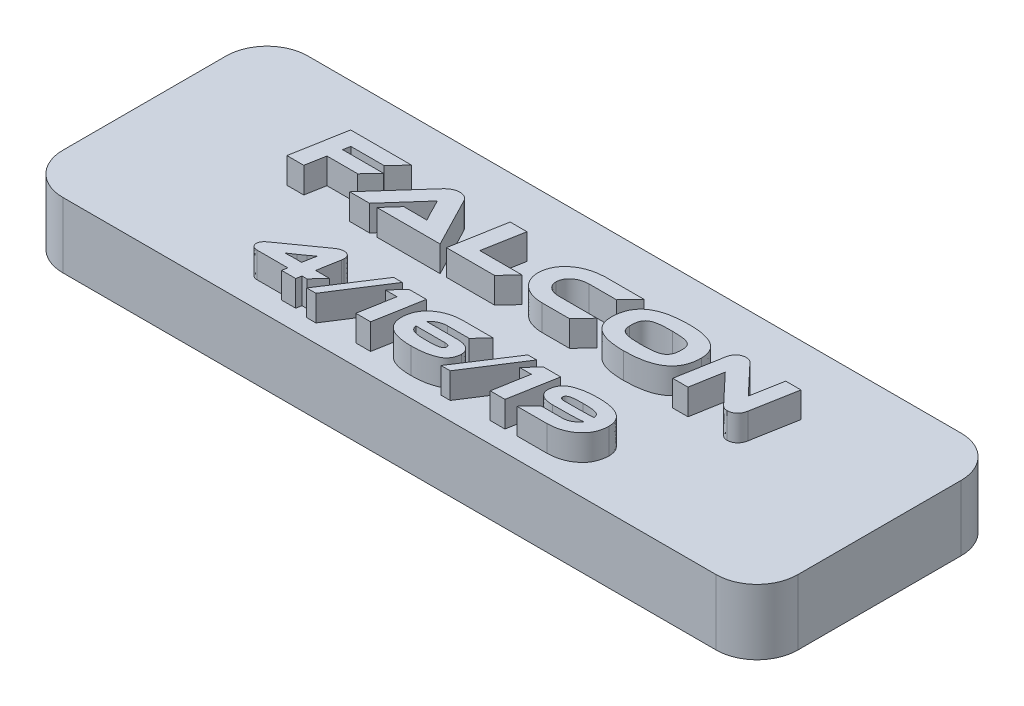
from build123d import *

# Parameters (mm, degrees)
SKETCH1_W           = 57.15
SKETCH1_H           = 19.05
BOSS_EXTRUDE1_DEPTH = 5.08
FILLET1_R           = 3.175
BOSS_EXTRUDE2_DEPTH = 2
SKETCH4_R           = 0.9
CUT_EXTRUDE1_DEPTH  = 4


with BuildPart() as part:
    # Sketch1 → Boss-Extrude1 (new body)
    with BuildSketch(Plane(origin=(0, 0, 0), x_dir=(1, 0, 0), z_dir=(0, 1, 0))):
        Rectangle(SKETCH1_W, SKETCH1_H)
    extrude(amount=BOSS_EXTRUDE1_DEPTH)

    # Fillet1
    fillet1_edges = [part.edges().sort_by_distance(p)[0] for p in [
        (-28.575, 2.54, -9.525),
        (-28.575, 2.54, 9.525),
        (28.575, 2.54, 9.525),
        (28.575, 2.54, -9.525),
    ]]
    fillet(fillet1_edges, radius=FILLET1_R)

    # Sketch3 → Boss-Extrude2 (add)
    with BuildSketch(Plane(origin=(0, 5.08, 0), x_dir=(1, 0, 0), z_dir=(0, 1, 0))):
        with BuildLine():
            add(Edge.make_bspline(
                [(16.780266279, -0.054850168), (16.828009676, -0.053307756), (16.922711817, -0.05024828), (17.060768199, -0.013632566), (17.191682911, 0.045846546), (17.292948445, 0.114571327), (17.369813108, 0.180074196), (17.42146539, 0.239380304), (17.469141377, 0.304525883), (17.512820124, 0.37632488), (17.549549759, 0.456142621), (17.58266638, 0.542520209), (17.611096033, 0.636006561), (17.625642107, 0.701351948), (17.633127874, 0.73498029)],
                knots=[0, 0, 0, 0, 0.000142918, 0.000283487, 0.000425039, 0.000572601, 0.000649052, 0.000727397, 0.000807848, 0.000891096, 0.000979017, 0.001071034, 0.001168489, 0.001271817, 0.001271817, 0.001271817, 0.001271817], degree=3))
            Line((17.633127874, 0.73498029), (18.258850622, 4.208766837))
            Line((18.258850622, 4.208766837), (17.070928158, 4.208766837))
            Line((17.070928158, 4.208766837), (16.628616603, 1.744535481))
            Line((16.628616603, 1.744535481), (14.448652508, 4.051761679))
            add(Edge.make_bspline(
                [(14.448652508, 4.051761679), (14.427813381, 4.071861366), (14.387749108, 4.110504029), (14.325171244, 4.159915527), (14.263133498, 4.198286334), (14.183296116, 4.234148727), (14.083019548, 4.262967857), (14.001697117, 4.265244744), (13.961883043, 4.266359469)],
                knots=[0, 0, 0, 0, 8.6821e-05, 0.000166918, 0.000238724, 0.000304999, 0.000429193, 0.000548317, 0.000548317, 0.000548317, 0.000548317], degree=3))
            add(Edge.make_bspline(
                [(13.961883043, 4.266359469), (13.912605999, 4.264808905), (13.815559411, 4.261755212), (13.674416698, 4.225895662), (13.540680994, 4.169094021), (13.438121991, 4.10078741), (13.361606759, 4.035125752), (13.309731394, 3.976716804), (13.261583005, 3.912614286), (13.219520308, 3.840326612), (13.182204708, 3.76109782), (13.150633382, 3.674633708), (13.122418598, 3.581734028), (13.109335945, 3.516584051), (13.102577729, 3.482928986)],
                knots=[0, 0, 0, 0, 0.000147522, 0.000290531, 0.000433852, 0.000581668, 0.000658119, 0.000735785, 0.0008155, 0.00089828, 0.000986201, 0.001077895, 0.001174211, 0.001277134, 0.001277134, 0.001277134, 0.001277134], degree=3))
            Line((13.102577729, 3.482928986), (12.48984419, 0.003655726))
            Line((12.48984419, 0.003655726), (13.677766654, 0.003655726))
            Line((13.677766654, 0.003655726), (14.113759473, 2.467622834))
            Line((14.113759473, 2.467622834), (16.293723568, 0.160396636))
            add(Edge.make_bspline(
                [(16.293723568, 0.160396636), (16.314440673, 0.140042889), (16.354045572, 0.101132624), (16.416177124, 0.052046216), (16.47573695, 0.012533377), (16.553265822, -0.024191848), (16.654960002, -0.051598076), (16.737989767, -0.054359084), (16.780266279, -0.054850168)],
                knots=[0, 0, 0, 0, 8.7067e-05, 0.000166446, 0.000237191, 0.000300979, 0.000423168, 0.000549653, 0.000549653, 0.000549653, 0.000549653], degree=3))
        make_face()
        with BuildLine():
            add(Edge.make_bspline(
                [(9.496039689, 4.264853435), (9.422966975, 4.264150041), (9.279462864, 4.262768679), (9.068001233, 4.255304453), (8.863725494, 4.243828802), (8.666531346, 4.226275073), (8.476304033, 4.204448808), (8.292999458, 4.178135377), (8.116702708, 4.146346882), (7.947565312, 4.108703546), (7.785589212, 4.066841285), (7.630726648, 4.020018599), (7.482516888, 3.969271115), (7.341257794, 3.912462076), (7.207363574, 3.850145336), (7.079594109, 3.784672178), (6.959544845, 3.713307743), (6.847056036, 3.636054084), (6.740530204, 3.555015487), (6.641809484, 3.467997248), (6.549955969, 3.375795294), (6.463884658, 3.27972572), (6.38614356, 3.176938462), (6.313458319, 3.070861845), (6.250017547, 2.958180712), (6.190488837, 2.842029764), (6.139796027, 2.71956376), (6.096078177, 2.592115874), (6.058140919, 2.460138961), (6.02847549, 2.322911611), (6.004600111, 2.180763117), (5.987270576, 2.033740252), (5.976946139, 1.881481624), (5.976205213, 1.778351657), (5.975828551, 1.725923865)],
                knots=[0, 0, 0, 0, 0.00021922, 0.000430517, 0.000634719, 0.000832939, 0.001024345, 0.001209088, 0.001388397, 0.001561619, 0.0017288, 0.001890173, 0.002046865, 0.002198625, 0.002346687, 0.00248979, 0.002629165, 0.002765325, 0.002898982, 0.003030471, 0.003159752, 0.003289265, 0.003417071, 0.003546125, 0.003674706, 0.003804712, 0.003937476, 0.004071906, 0.004208776, 0.004349179, 0.004492852, 0.004641052, 0.004793135, 0.004950393, 0.004950393, 0.004950393, 0.004950393], degree=3))
            add(Edge.make_bspline(
                [(5.975828551, 1.725923865), (5.977756992, 1.652651179), (5.981498211, 1.510500548), (6.015537081, 1.304743113), (6.068725934, 1.113533359), (6.14442286, 0.936607339), (6.241975517, 0.774301847), (6.361810325, 0.627005612), (6.503767588, 0.495143384), (6.666657174, 0.377875494), (6.851095344, 0.275513814), (7.05651962, 0.187096535), (7.282704131, 0.111278664), (7.53053192, 0.05083109), (7.798977563, 0.003624777), (8.088662872, -0.029580863), (8.399569375, -0.049844784), (8.614046343, -0.051940053), (8.724691401, -0.053020966)],
                knots=[0, 0, 0, 0, 0.000219671, 0.000426167, 0.000623813, 0.000813827, 0.001001645, 0.001190103, 0.001381548, 0.00158123, 0.001790776, 0.002013083, 0.002251287, 0.002505594, 0.002777627, 0.003068474, 0.003379936, 0.003711836, 0.003711836, 0.003711836, 0.003711836], degree=3))
            add(Edge.make_bspline(
                [(8.724691401, -0.053020966), (8.797526067, -0.052455169), (8.940794073, -0.051342229), (9.152314687, -0.043724787), (9.356604575, -0.032438481), (9.553772066, -0.014624257), (9.744093932, 0.006825126), (9.927265684, 0.034388638), (10.103600918, 0.066140884), (10.272466839, 0.103671999), (10.434647572, 0.145843098), (10.590159049, 0.191939017), (10.738202104, 0.24436261), (10.879477809, 0.30061376), (11.013060988, 0.363320067), (11.140472785, 0.429548791), (11.260223208, 0.501958418), (11.373001359, 0.579052293), (11.479431476, 0.660209293), (11.578536557, 0.747143393), (11.669745373, 0.84029394), (11.756172858, 0.93631177), (11.833868558, 1.03914999), (11.90652582, 1.145233071), (11.97025848, 1.258074334), (12.029279808, 1.374784654), (12.080257156, 1.497412041), (12.123929499, 1.624884051), (12.161864706, 1.756856749), (12.191650752, 1.894369804), (12.215319165, 2.036857562), (12.232761347, 2.184166254), (12.243064568, 2.336428379), (12.24380842, 2.439557863), (12.24418657, 2.491985411)],
                knots=[0, 0, 0, 0, 0.0002185, 0.000429796, 0.000634912, 0.000832221, 0.001023627, 0.001209407, 0.001387817, 0.001561039, 0.001728219, 0.001890468, 0.002047461, 0.002199222, 0.002346454, 0.00248998, 0.002629824, 0.002765984, 0.002899642, 0.003031131, 0.00316106, 0.003290573, 0.003418378, 0.003547433, 0.003676014, 0.003806837, 0.003939601, 0.004074031, 0.004210901, 0.004351303, 0.004495879, 0.004644079, 0.004796161, 0.00495342, 0.00495342, 0.00495342, 0.00495342], degree=3))
            add(Edge.make_bspline(
                [(12.24418657, 2.491985411), (12.242105639, 2.564930001), (12.238053197, 2.706983534), (12.205921842, 2.912703512), (12.151924556, 3.104122883), (12.075935536, 3.280748696), (11.977982074, 3.44245971), (11.858843079, 3.589369287), (11.717433844, 3.721034434), (11.553921911, 3.837071522), (11.36988913, 3.940135668), (11.163846554, 4.0266221), (10.937979748, 4.102333874), (10.689961762, 4.161421518), (10.421343254, 4.208718585), (10.131386896, 4.242297194), (9.820406294, 4.261022072), (9.605961896, 4.263336881), (9.496039689, 4.264853435)],
                knots=[0, 0, 0, 0, 0.000218758, 0.000426013, 0.00062278, 0.000813995, 0.001001031, 0.001188203, 0.001379648, 0.001578795, 0.001788342, 0.002011126, 0.002248172, 0.002502261, 0.002775194, 0.003066041, 0.003377445, 0.003709345, 0.003709345, 0.003709345, 0.003709345], degree=3))
        make_face()
        with BuildLine():
            add(Edge.make_bspline(
                [(8.91471593, 1.047030173), (8.846195292, 1.04660261), (8.714276038, 1.045779446), (8.523416215, 1.049733712), (8.347251806, 1.061186797), (8.185148154, 1.075736974), (8.037480131, 1.097737934), (7.904153413, 1.125013299), (7.784313682, 1.156348623), (7.678448073, 1.194530349), (7.584599376, 1.240026498), (7.504703992, 1.297252332), (7.436098008, 1.363776891), (7.382195021, 1.441900597), (7.339325071, 1.529303822), (7.309500361, 1.627061382), (7.291915256, 1.735031597), (7.29090669, 1.81026116), (7.29038285, 1.849334734)],
                knots=[0, 0, 0, 0, 0.000205565, 0.000395764, 0.000572537, 0.000735087, 0.000883892, 0.001020147, 0.001143219, 0.001255139, 0.001357344, 0.001455005, 0.001548736, 0.001642574, 0.001738242, 0.001839729, 0.001948086, 0.002065187, 0.002065187, 0.002065187, 0.002065187], degree=3))
            add(Edge.make_bspline(
                [(7.29038285, 1.849334734), (7.28873433, 1.911811071), (7.28557848, 2.031412847), (7.297476265, 2.203375738), (7.322437279, 2.359667266), (7.361285958, 2.50079582), (7.414551249, 2.626166729), (7.480115864, 2.737052728), (7.561928012, 2.83042282), (7.641134092, 2.895436203), (7.71178484, 2.940784123), (7.772281923, 2.971515459), (7.839372447, 2.999666566), (7.912637304, 3.026084681), (7.99215494, 3.05083148), (8.078211737, 3.072755525), (8.171151839, 3.09131218), (8.270244238, 3.110411596), (8.376577823, 3.124111193), (8.48896002, 3.137374608), (8.608211033, 3.147018552), (8.733772388, 3.155167115), (8.866021782, 3.161792983), (9.004705933, 3.165320712), (9.150079568, 3.166041701), (9.249111973, 3.165221911), (9.299694638, 3.164803188)],
                knots=[0, 0, 0, 0, 0.000187411, 0.00035877, 0.00051627, 0.000661555, 0.000796714, 0.00092386, 0.001046319, 0.001167112, 0.001230003, 0.001297872, 0.001370374, 0.001448163, 0.001531436, 0.001620123, 0.001714428, 0.001815734, 0.00192278, 0.002035947, 0.002155212, 0.002281633, 0.002413427, 0.002552426, 0.00269778, 0.002849532, 0.002849532, 0.002849532, 0.002849532], degree=3))
            add(Edge.make_bspline(
                [(9.299694638, 3.164803188), (9.368559888, 3.165086646), (9.501737734, 3.165634822), (9.694160203, 3.161832074), (9.871852792, 3.150341942), (10.035147755, 3.135653139), (10.183797083, 3.114010286), (10.317931417, 3.086275793), (10.437965422, 3.055550786), (10.54358555, 3.01670025), (10.637134078, 2.971781209), (10.7163785, 2.913989507), (10.784704553, 2.847457656), (10.839901962, 2.770130915), (10.881548215, 2.682069422), (10.910305027, 2.584313015), (10.928162923, 2.476491904), (10.929129986, 2.401253582), (10.929632271, 2.362175459)],
                knots=[0, 0, 0, 0, 0.000206599, 0.00039954, 0.000577225, 0.000740685, 0.000891298, 0.001027553, 0.001151508, 0.001262569, 0.001364775, 0.001461693, 0.001555424, 0.00164979, 0.00174506, 0.001846279, 0.001954636, 0.002071737, 0.002071737, 0.002071737, 0.002071737], degree=3))
            add(Edge.make_bspline(
                [(10.929632271, 2.362175459), (10.931254644, 2.300007823), (10.934359778, 2.181022384), (10.922788079, 2.009565903), (10.896561285, 1.85401663), (10.857628122, 1.713235889), (10.804733494, 1.587793863), (10.73796533, 1.477427264), (10.655936337, 1.383606431), (10.576469765, 1.317707612), (10.504731357, 1.272767382), (10.443886333, 1.241979786), (10.377216755, 1.212524455), (10.303432095, 1.186264377), (10.223566102, 1.161664348), (10.136822766, 1.139884782), (10.043906067, 1.119635522), (9.944068854, 1.102726509), (9.83806692, 1.086938186), (9.725249672, 1.074209563), (9.606013167, 1.064550242), (9.480151635, 1.056272217), (9.347897448, 1.049750773), (9.20891042, 1.046182113), (9.063536387, 1.045470465), (8.964504037, 1.046288949), (8.91471593, 1.047030173)],
                knots=[0, 0, 0, 0, 0.000186496, 0.000356944, 0.000514595, 0.000659, 0.000794159, 0.000921781, 0.00104424, 0.00116632, 0.001229983, 0.001297853, 0.001370716, 0.001448505, 0.001532652, 0.001621339, 0.001716727, 0.001817873, 0.001925047, 0.002038214, 0.00215839, 0.002283899, 0.002416606, 0.002555606, 0.002700959, 0.002852711, 0.002852711, 0.002852711, 0.002852711], degree=3))
        make_face(mode=Mode.SUBTRACT)
        with BuildLine():
            add(Edge.make_bspline(
                [(2.533352691, 1.105536066), (2.493631661, 1.106368572), (2.416216179, 1.107991107), (2.303389092, 1.120099472), (2.197144099, 1.139341634), (2.09673251, 1.164731953), (2.002199599, 1.197730851), (1.913689506, 1.237674392), (1.831391916, 1.284870974), (1.755586613, 1.338214411), (1.688115375, 1.398892985), (1.628130206, 1.463686553), (1.577372546, 1.534061863), (1.534888764, 1.609307897), (1.50205177, 1.690172386), (1.478239958, 1.775740301), (1.463466337, 1.866215268), (1.460506531, 1.928202108), (1.458990725, 1.95994744)],
                knots=[0, 0, 0, 0, 0.000119146, 0.000232213, 0.000339979, 0.000442857, 0.0005426, 0.00063997, 0.000733741, 0.000826832, 0.000917476, 0.001005473, 0.001091233, 0.001177183, 0.0012641, 0.001352376, 0.001443149, 0.001538437, 0.001538437, 0.001538437, 0.001538437], degree=3))
            add(Edge.make_bspline(
                [(1.458990725, 1.95994744), (1.461368345, 2.00089212), (1.466052282, 2.08155355), (1.489811634, 2.199187811), (1.524292501, 2.311187764), (1.571268942, 2.41754111), (1.631397542, 2.517456178), (1.70282181, 2.612420697), (1.787992837, 2.700160835), (1.883352982, 2.782047564), (1.988380111, 2.855559397), (2.099862609, 2.920673089), (2.217775515, 2.975739929), (2.341386276, 3.021270473), (2.470846924, 3.058247704), (2.606350529, 3.084423964), (2.747858519, 3.10108536), (2.844194521, 3.104537604), (2.893299275, 3.106297295)],
                knots=[0, 0, 0, 0, 0.000122909, 0.000242131, 0.000358943, 0.000473945, 0.00058996, 0.00070807, 0.000829622, 0.000956043, 0.00108463, 0.001213669, 0.001342898, 0.001474501, 0.001608483, 0.001746351, 0.001888089, 0.00203545, 0.00203545, 0.00203545, 0.00203545], degree=3))
            Line((2.893299275, 3.106297295), (5.016616139, 3.106887389))
            Line((5.016616139, 3.106887389), (6.052888926, 4.206347541))
            Line((6.052888926, 4.206347541), (3.089401504, 4.206347541))
            add(Edge.make_bspline(
                [(3.089401504, 4.206347541), (2.987381714, 4.202700375), (2.787573838, 4.195557324), (2.494357924, 4.162353327), (2.214220818, 4.110015155), (1.947359869, 4.036172143), (1.692751109, 3.945267581), (1.451624458, 3.833094278), (1.222983169, 3.702119343), (1.044070636, 3.576781715), (0.908536696, 3.469194079), (0.814459071, 3.383435035), (0.72562953, 3.295964452), (0.642830394, 3.205335074), (0.567327497, 3.110727377), (0.496141715, 3.01426649), (0.433603271, 2.913020304), (0.375436808, 2.809716549), (0.324241484, 2.702914965), (0.280398221, 2.592415367), (0.242239813, 2.479140843), (0.208696707, 2.363167205), (0.183736663, 2.243547853), (0.16303849, 2.121372678), (0.150603829, 1.99550854), (0.146509416, 1.910604524), (0.144436425, 1.867617826)],
                knots=[0, 0, 0, 0, 0.000306166, 0.000599632, 0.000884344, 0.001160233, 0.001429449, 0.00169448, 0.001956971, 0.002218938, 0.002348999, 0.002475859, 0.002600617, 0.002722926, 0.00284385, 0.002963619, 0.003082322, 0.003200591, 0.003319167, 0.003437316, 0.003556997, 0.003677669, 0.003799234, 0.003923371, 0.004049262, 0.004178365, 0.004178365, 0.004178365, 0.004178365], degree=3))
            add(Edge.make_bspline(
                [(0.144436425, 1.867617826), (0.147436299, 1.801688472), (0.153341258, 1.671912941), (0.183791765, 1.482185543), (0.232444881, 1.301387781), (0.299251159, 1.130003576), (0.384259437, 0.967607666), (0.486793486, 0.814264123), (0.609045742, 0.671011828), (0.74727701, 0.536982875), (0.901533515, 0.415938203), (1.069092906, 0.308972587), (1.24979878, 0.218224767), (1.444028683, 0.144692398), (1.650198561, 0.084618858), (1.870033461, 0.042789332), (2.102101696, 0.013380635), (2.261524947, 0.00815489), (2.342978213, 0.005484928)],
                knots=[0, 0, 0, 0, 0.000197872, 0.000389491, 0.000575101, 0.000758611, 0.000940158, 0.001123976, 0.001310786, 0.001504088, 0.001700684, 0.001897981, 0.00209953, 0.002306142, 0.002520237, 0.002742905, 0.002976823, 0.003221191, 0.003221191, 0.003221191, 0.003221191], degree=3))
            Line((2.342978213, 0.005484928), (4.466886063, 0.006075914))
            Line((4.466886063, 0.006075914), (5.496840113, 1.105536066))
            Line((5.496840113, 1.105536066), (2.533352691, 1.105536066))
        make_face()
        Polygon((-3.603933057, 1.105536066), (-3.047884245, 4.208766837), (-4.349543965, 4.208766837), (-5.10147361, 0.006075914), (-1.367100334, 0.006075914), (-0.32450881, 1.105536066), align=None)
        with BuildLine():
            Line((-5.593519103, 0.006075914), (-7.558646157, 3.800574494))
            add(Edge.make_bspline(
                [(-7.558646157, 3.800574494), (-7.576767101, 3.832806008), (-7.612725764, 3.896765269), (-7.677599454, 3.985575321), (-7.754858941, 4.0630874), (-7.839761852, 4.133983071), (-7.937567746, 4.192399523), (-8.049678896, 4.23493807), (-8.175720723, 4.260058315), (-8.264451656, 4.264204191), (-8.310579372, 4.266359469)],
                knots=[0, 0, 0, 0, 0.000110886, 0.000220038, 0.000328642, 0.000438436, 0.000551159, 0.000668641, 0.000796469, 0.000934872, 0.000934872, 0.000934872, 0.000934872], degree=3))
            add(Edge.make_bspline(
                [(-8.310579372, 4.266359469), (-8.360391032, 4.264009128), (-8.457122152, 4.259444915), (-8.597160908, 4.230967468), (-8.72743947, 4.187726952), (-8.847174345, 4.126959855), (-8.956856001, 4.055096369), (-9.060057355, 3.977511138), (-9.154363568, 3.892229282), (-9.211746071, 3.830720556), (-9.240274589, 3.800140628)],
                knots=[0, 0, 0, 0, 0.00014941, 0.000290146, 0.000427171, 0.000560039, 0.000691642, 0.000820174, 0.000947034, 0.001072464, 0.001072464, 0.001072464, 0.001072464], degree=3))
            Line((-9.240274589, 3.800140628), (-12.626272836, 0.006075914))
            Line((-12.626272836, 0.006075914), (-11.078182391, 0.006075914))
            Line((-11.078182391, 0.006075914), (-8.60123768, 2.798493231))
            Line((-8.60123768, 2.798493231), (-8.038870131, 1.696826253))
            add(Edge.make_bspline(
                [(-8.038870131, 1.696826253), (-8.012196126, 1.644325557), (-7.95767988, 1.5370248), (-7.888251538, 1.403208105), (-7.832168444, 1.297464771), (-7.79102733, 1.223921613), (-7.754623488, 1.155498073), (-7.729325183, 1.112747401), (-7.717293043, 1.092414734)],
                knots=[0, 0, 0, 0, 0.000176664, 0.000361065, 0.000452265, 0.000535729, 0.000613867, 0.000684736, 0.000684736, 0.000684736, 0.000684736], degree=3))
            add(Edge.make_bspline(
                [(-7.717293043, 1.092414734), (-7.772741388, 1.095166522), (-7.890901223, 1.101030553), (-8.075331759, 1.103502684), (-8.270350625, 1.10564963), (-8.402603222, 1.105358474), (-8.468728116, 1.105212899)],
                knots=[0, 0, 0, 0, 0.000166537, 0.000354888, 0.000553268, 0.00075164, 0.00075164, 0.00075164, 0.00075164], degree=3))
            Line((-8.468728116, 1.105212899), (-9.52377321, 1.105536066))
            Line((-9.52377321, 1.105536066), (-10.509496106, 0.006075914))
            Line((-10.509496106, 0.006075914), (-5.593519103, 0.006075914))
        make_face()
        Polygon((-16.752793434, 4.206347541), (-17.504723078, 0.003655726), (-16.190425885, 0.003655726), (-15.918720215, 1.53029389), (-13.523919079, 1.53029389), (-12.550833656, 2.565116885), (-15.735476856, 2.565116885), (-15.640695809, 3.106887389), (-13.056332577, 3.106887389), (-12.02005979, 4.206347541), align=None)
        with BuildLine():
            Line((9.216645947, -6.970155942), (8.321389987, -7.932183575))
            Line((8.321389987, -7.932183575), (10.639567627, -7.932183575))
            add(Edge.make_bspline(
                [(10.639567627, -7.932183575), (10.729413883, -7.929777147), (10.905983586, -7.92504793), (11.16499445, -7.89377972), (11.413033781, -7.845456505), (11.649522095, -7.778119368), (11.874794896, -7.693257531), (12.088471366, -7.589683886), (12.290554815, -7.467776465), (12.448735875, -7.351552012), (12.567971168, -7.251102183), (12.651320956, -7.171271707), (12.729845975, -7.089073015), (12.803061163, -7.003301544), (12.869800619, -6.913691428), (12.932134604, -6.821436558), (12.987696076, -6.725101624), (13.039350732, -6.626227548), (13.084010148, -6.523415525), (13.123181088, -6.417304195), (13.157821184, -6.308297587), (13.185425075, -6.195383605), (13.209176275, -6.079711014), (13.22522198, -5.960192069), (13.237859885, -5.837767761), (13.241207813, -5.75491021), (13.242900459, -5.713019076)],
                knots=[0, 0, 0, 0, 0.000269512, 0.000529657, 0.000781592, 0.001026938, 0.001266417, 0.001502887, 0.001738287, 0.001973466, 0.00209094, 0.002205793, 0.002319514, 0.002431869, 0.002543853, 0.002654555, 0.002765679, 0.002877297, 0.002989052, 0.003101677, 0.003216532, 0.003331962, 0.003450243, 0.003570604, 0.003693573, 0.003819318, 0.003819318, 0.003819318, 0.003819318], degree=3))
            add(Edge.make_bspline(
                [(13.242900459, -5.713019076), (13.240775339, -5.652117472), (13.236641548, -5.533651456), (13.208252922, -5.361744864), (13.16196414, -5.20161806), (13.097742857, -5.05300733), (13.015125193, -4.916595218), (12.915596853, -4.79126316), (12.795896092, -4.67984859), (12.660441805, -4.578328397), (12.505739322, -4.490460709), (12.334005181, -4.413762538), (12.14432535, -4.349318484), (11.937261374, -4.296844754), (11.712400408, -4.256528236), (11.469890699, -4.227593809), (11.209629312, -4.208531898), (11.030186838, -4.206884801), (10.937631123, -4.206035236)],
                knots=[0, 0, 0, 0, 0.00018267, 0.00035533, 0.000521131, 0.000681619, 0.000839513, 0.000998287, 0.001160113, 0.00132873, 0.001505033, 0.001692644, 0.001892226, 0.002105242, 0.002332894, 0.00257706, 0.002837673, 0.00311529, 0.00311529, 0.00311529, 0.00311529], degree=3))
            add(Edge.make_bspline(
                [(10.937631123, -4.206035236), (10.854432269, -4.205592276), (10.69089344, -4.204721577), (10.449654818, -4.215578286), (10.216833991, -4.234927868), (9.992407839, -4.265660573), (9.77626054, -4.305110003), (9.568838998, -4.355643498), (9.36991879, -4.415783415), (9.210474274, -4.473503284), (9.088614056, -4.525130752), (9.00414771, -4.569635858), (8.924140034, -4.616422557), (8.850933005, -4.668834502), (8.782053468, -4.723868288), (8.719845178, -4.784450305), (8.661877414, -4.847987079), (8.610512358, -4.916899938), (8.564130772, -4.989145242), (8.523949913, -5.066161285), (8.488707519, -5.146801308), (8.459142412, -5.2318633), (8.435138393, -5.32088445), (8.416872863, -5.41389817), (8.403849251, -5.510872203), (8.399968912, -5.57700115), (8.397995405, -5.610633762)],
                knots=[0, 0, 0, 0, 0.000249565, 0.000490555, 0.000724179, 0.0009502, 0.001169841, 0.001383052, 0.001590297, 0.00179299, 0.001891509, 0.001987031, 0.002079216, 0.002169319, 0.002256891, 0.002343445, 0.002429536, 0.002514644, 0.002600961, 0.002686833, 0.002774954, 0.002864759, 0.002956732, 0.003051325, 0.003148954, 0.003249996, 0.003249996, 0.003249996, 0.003249996], degree=3))
            add(Edge.make_bspline(
                [(8.397995405, -5.610633762), (8.399430259, -5.643753438), (8.402235756, -5.708510641), (8.418117149, -5.802650158), (8.445104564, -5.890402518), (8.479907781, -5.972873051), (8.526025163, -6.048807605), (8.582589512, -6.117637999), (8.648200606, -6.18094304), (8.723665106, -6.237416652), (8.807631167, -6.287658407), (8.89965712, -6.330947125), (8.999263513, -6.367615523), (9.106702308, -6.398128227), (9.222077394, -6.420818141), (9.344936213, -6.437537883), (9.475263071, -6.448004733), (9.564741654, -6.449663014), (9.610621467, -6.450513291)],
                knots=[0, 0, 0, 0, 9.9392e-05, 0.000194336, 0.000285432, 0.000374287, 0.00046222, 0.000550917, 0.000640864, 0.000735091, 0.000833037, 0.000933937, 0.001039728, 0.001151139, 0.001268635, 0.001392165, 0.00152296, 0.001660599, 0.001660599, 0.001660599, 0.001660599], degree=3))
            add(Edge.make_bspline(
                [(9.610621467, -6.450513291), (9.664213973, -6.450588766), (9.769000015, -6.450736339), (9.922576717, -6.449683936), (10.069489033, -6.448934551), (10.209469244, -6.448155746), (10.342782533, -6.447263447), (10.469170212, -6.446777451), (10.588881136, -6.444902162), (10.701933041, -6.443402764), (10.808048314, -6.441665317), (10.907249814, -6.440519694), (10.999742893, -6.437415789), (11.085358911, -6.436504009), (11.16426834, -6.433778787), (11.236254631, -6.43134803), (11.301611358, -6.429349577), (11.378351748, -6.424605461), (11.46561015, -6.420771207), (11.562878574, -6.413793257), (11.651477927, -6.408049685), (11.731351845, -6.400065169), (11.802737513, -6.394706302), (11.865028783, -6.386176476), (11.918689911, -6.378534723), (11.951367876, -6.372485855), (11.966283575, -6.369724879)],
                knots=[0, 0, 0, 0, 0.000160777, 0.000314357, 0.000460738, 0.00060152, 0.000734304, 0.000860688, 0.000980681, 0.001093477, 0.001199873, 0.001299072, 0.00139109, 0.001477493, 0.001555918, 0.001627948, 0.001693582, 0.001752061, 0.001858593, 0.001955591, 0.002044608, 0.00212492, 0.002196397, 0.002259299, 0.002313485, 0.002358987, 0.002358987, 0.002358987, 0.002358987], degree=3))
            add(Edge.make_bspline(
                [(11.966283575, -6.369724879), (11.936562519, -6.410755391), (11.876717246, -6.493372984), (11.769023145, -6.604032197), (11.649099052, -6.70577684), (11.538556089, -6.780745718), (11.443600047, -6.833676621), (11.368800294, -6.868964979), (11.291559839, -6.899761591), (11.21066792, -6.923136897), (11.127591739, -6.943784293), (11.040874327, -6.957621584), (10.951457388, -6.967749518), (10.890733276, -6.969535864), (10.860042252, -6.970438714)],
                knots=[0, 0, 0, 0, 0.000151822, 0.000305704, 0.000461788, 0.000623076, 0.000705429, 0.000787724, 0.000871054, 0.000954565, 0.001040123, 0.001127702, 0.001217802, 0.001309875, 0.001309875, 0.001309875, 0.001309875], degree=3))
            Line((10.860042252, -6.970438714), (9.216645947, -6.970155942))
        make_face()
        with BuildLine():
            add(Edge.make_bspline(
                [(9.826820144, -5.739416071), (9.798435126, -5.739333167), (9.745246411, -5.739177819), (9.671496082, -5.728388524), (9.608608679, -5.712937853), (9.556685533, -5.691097621), (9.515566299, -5.66209877), (9.487351559, -5.625127048), (9.46921927, -5.582069955), (9.468048573, -5.550830586), (9.467442005, -5.534644662)],
                knots=[0, 0, 0, 0, 8.5051e-05, 0.000159372, 0.000223007, 0.000278884, 0.00032752, 0.000371998, 0.000416856, 0.000465088, 0.000465088, 0.000465088, 0.000465088], degree=3))
            add(Edge.make_bspline(
                [(9.467442005, -5.534644662), (9.466239719, -5.520492659), (9.463885793, -5.492784798), (9.471832468, -5.451904192), (9.487112356, -5.413284736), (9.51202669, -5.377865243), (9.544313693, -5.344746874), (9.585578597, -5.315137149), (9.634207014, -5.287204256), (9.692690716, -5.262102266), (9.76318566, -5.239181686), (9.849324548, -5.220969825), (9.951266682, -5.204302076), (10.069538273, -5.19102051), (10.204006097, -5.180808804), (10.354997262, -5.174134861), (10.522189876, -5.169033665), (10.639002714, -5.168550026), (10.700065199, -5.16829721)],
                knots=[0, 0, 0, 0, 4.2424e-05, 8.3061e-05, 0.000123611, 0.000166209, 0.000212026, 0.00026178, 0.000318034, 0.000380003, 0.000452348, 0.000540062, 0.000643816, 0.000762183, 0.000896965, 0.001048315, 0.00121556, 0.00139874, 0.00139874, 0.00139874, 0.00139874], degree=3))
            add(Edge.make_bspline(
                [(10.700065199, -5.16829721), (10.752591728, -5.167787601), (10.854717644, -5.166796781), (11.003262441, -5.169363834), (11.142542538, -5.174373781), (11.272368918, -5.184530804), (11.393065188, -5.195834798), (11.504447817, -5.211544935), (11.606187336, -5.232098586), (11.699400284, -5.253456427), (11.783021044, -5.280784321), (11.856510998, -5.316195779), (11.91915331, -5.359607715), (11.972721544, -5.409671023), (12.014462561, -5.468468051), (12.047317214, -5.534032814), (12.06776405, -5.607713922), (12.073646014, -5.659314386), (12.076667742, -5.685822977)],
                knots=[0, 0, 0, 0, 0.000157579, 0.000306377, 0.00044567, 0.000575606, 0.000696984, 0.000809313, 0.000912848, 0.001008299, 0.001096072, 0.001176204, 0.001252088, 0.00132394, 0.001394981, 0.001467241, 0.001542944, 0.00162292, 0.00162292, 0.00162292, 0.00162292], degree=3))
            add(Edge.make_bspline(
                [(12.076667742, -5.685822977), (12.059077037, -5.688016622), (12.021529572, -5.692698971), (11.961772488, -5.698817251), (11.895197693, -5.705774202), (11.821770625, -5.709867374), (11.741794868, -5.714809123), (11.655158317, -5.719762177), (11.561827556, -5.723691176), (11.458627951, -5.726773296), (11.339458092, -5.730355113), (11.19786108, -5.73231403), (11.030953695, -5.734779827), (10.838984201, -5.737306699), (10.621678726, -5.738848781), (10.379044438, -5.739352636), (10.11108381, -5.740463735), (9.924176628, -5.740300435), (9.826820144, -5.739416071)],
                knots=[0, 0, 0, 0, 5.3179e-05, 0.000113511, 0.000180209, 0.000253954, 0.000334087, 0.000420608, 0.00051428, 0.000614317, 0.000730344, 0.000871944, 0.001039137, 0.001231125, 0.0014479, 0.001691066, 0.001959029, 0.002251787, 0.002251787, 0.002251787, 0.002251787], degree=3))
        make_face(mode=Mode.SUBTRACT)
        Polygon((5.820204221, -5.218973535), (6.721414016, -5.218973535), (6.240400199, -7.93430124), (7.384881349, -7.93430124), (8.042819788, -4.256945902), (6.688240649, -4.256945902), align=None)
        Polygon((5.288243025, -4.05005839), (2.623315903, -8.139071868), (3.336543286, -8.139071868), (5.962768147, -4.05005839), align=None)
        with BuildLine():
            Line((0.191360052, -5.218973535), (1.890049207, -5.218973535))
            Line((1.890049207, -5.218973535), (2.791510528, -4.256945902))
            Line((2.791510528, -4.256945902), (0.418044724, -4.256945902))
            add(Edge.make_bspline(
                [(0.418044724, -4.256945902), (0.328739018, -4.259739626), (0.153553627, -4.265219899), (-0.103290346, -4.29541853), (-0.348868099, -4.342221395), (-0.583246943, -4.407138786), (-0.80678223, -4.489329122), (-1.018515022, -4.591047855), (-1.220073444, -4.708377481), (-1.377500102, -4.82124577), (-1.495942459, -4.919078695), (-1.579536411, -4.99623817), (-1.657567559, -5.076563117), (-1.730200124, -5.16043671), (-1.797000041, -5.247386735), (-1.85926407, -5.337282161), (-1.914806263, -5.430833407), (-1.965762141, -5.527260267), (-2.010440499, -5.627271866), (-2.049396229, -5.73080087), (-2.084351181, -5.837034004), (-2.111759363, -5.947091767), (-2.135309627, -6.059882085), (-2.15275815, -6.176315937), (-2.164932942, -6.295911317), (-2.16836088, -6.376897212), (-2.170088726, -6.417717995)],
                knots=[0, 0, 0, 0, 0.000267948, 0.000525616, 0.00077489, 0.001017276, 0.001254416, 0.001488404, 0.001721073, 0.001953256, 0.002068575, 0.002181787, 0.002294355, 0.002404367, 0.002514441, 0.002623158, 0.002732215, 0.002840626, 0.002950187, 0.003060565, 0.003172372, 0.003285475, 0.00340062, 0.003517931, 0.003638512, 0.003761062, 0.003761062, 0.003761062, 0.003761062], degree=3))
            add(Edge.make_bspline(
                [(-2.170088726, -6.417717995), (-2.168331906, -6.482354672), (-2.164924065, -6.607735541), (-2.136153299, -6.789049915), (-2.090919579, -6.957482105), (-2.027586064, -7.113434337), (-1.945356902, -7.256435661), (-1.844324003, -7.386073128), (-1.725894885, -7.502991643), (-1.588794435, -7.6059022), (-1.434622297, -7.696261209), (-1.262843046, -7.773320924), (-1.074754848, -7.840300996), (-0.868932924, -7.89274563), (-0.646105732, -7.934453363), (-0.406166219, -7.963267725), (-0.149052467, -7.981122174), (0.027965039, -7.982950963), (0.119182905, -7.983893345)],
                knots=[0, 0, 0, 0, 0.00019381, 0.000375949, 0.000549231, 0.000716041, 0.000879446, 0.001042486, 0.001207646, 0.001377224, 0.001555426, 0.001742637, 0.001941235, 0.002153677, 0.002379115, 0.002620899, 0.002878265, 0.003151883, 0.003151883, 0.003151883, 0.003151883], degree=3))
            add(Edge.make_bspline(
                [(0.119182905, -7.983893345), (0.202381759, -7.984336305), (0.365920588, -7.985207004), (0.60715921, -7.974350295), (0.839980037, -7.955000713), (1.06440619, -7.924268009), (1.280553483, -7.884818573), (1.487975049, -7.834285099), (1.686895172, -7.774145108), (1.846339943, -7.71642546), (1.968199659, -7.664797558), (2.052667458, -7.620293709), (2.132669931, -7.573502509), (2.205895652, -7.521106731), (2.274707884, -7.466014736), (2.33703472, -7.405769547), (2.394237711, -7.341313522), (2.44612254, -7.272999226), (2.491740006, -7.20014095), (2.533263685, -7.124220099), (2.567020058, -7.042880957), (2.596960864, -6.95810596), (2.620850897, -6.869032788), (2.639148218, -6.776033577), (2.652163063, -6.679055543), (2.656044614, -6.612927149), (2.658018738, -6.579294819)],
                knots=[0, 0, 0, 0, 0.000249565, 0.000490555, 0.000724179, 0.0009502, 0.001169841, 0.001383052, 0.001590297, 0.00179299, 0.001891509, 0.001987031, 0.002079216, 0.002169319, 0.002256891, 0.002343445, 0.002429003, 0.002515231, 0.002600444, 0.002686691, 0.002774497, 0.002864301, 0.002956274, 0.003050867, 0.003148496, 0.003249538, 0.003249538, 0.003249538, 0.003249538], degree=3))
            add(Edge.make_bspline(
                [(2.658018738, -6.579294819), (2.656522278, -6.546179963), (2.653598307, -6.481475999), (2.638603944, -6.387387353), (2.612936785, -6.299153452), (2.576554352, -6.217487588), (2.531714548, -6.141135206), (2.475826491, -6.072044673), (2.410258878, -6.009259639), (2.335601017, -5.952501104), (2.252233212, -5.902055271), (2.160536862, -5.85920237), (2.061355625, -5.822118238), (1.954341615, -5.791947815), (1.839548983, -5.769071225), (1.717213754, -5.752394052), (1.587162009, -5.74172829), (1.497673343, -5.740728021), (1.451791757, -5.740215175)],
                knots=[0, 0, 0, 0, 9.9392e-05, 0.000194205, 0.000285072, 0.000374247, 0.000461768, 0.000549962, 0.000639909, 0.000733499, 0.00083076, 0.00093166, 0.001036701, 0.001148112, 0.001264824, 0.001387562, 0.001518357, 0.001655975, 0.001655975, 0.001655975, 0.001655975], degree=3))
            Line((1.451791757, -5.740215175), (-0.886774365, -5.739416071))
            add(Edge.make_bspline(
                [(-0.886774365, -5.739416071), (-0.856651639, -5.700690699), (-0.796264287, -5.623057528), (-0.687607703, -5.521790136), (-0.567021416, -5.431922714), (-0.433030807, -5.357362491), (-0.289222527, -5.296260969), (-0.13620311, -5.252201841), (0.024921232, -5.225297334), (0.13507644, -5.221449409), (0.191360052, -5.218973535)],
                knots=[0, 0, 0, 0, 0.000146983, 0.000294659, 0.000443921, 0.000597209, 0.000753496, 0.000911714, 0.001073854, 0.001242104, 0.001242104, 0.001242104, 0.001242104], degree=3))
        make_face()
        with BuildLine():
            add(Edge.make_bspline(
                [(1.236321102, -6.449714187), (1.263910342, -6.450592724), (1.315703064, -6.452241983), (1.388058572, -6.461304846), (1.449805323, -6.47706035), (1.501032115, -6.498767021), (1.541304998, -6.528101114), (1.569481721, -6.564775752), (1.587589501, -6.607865665), (1.588763661, -6.639100397), (1.589372023, -6.655283919)],
                knots=[0, 0, 0, 0, 8.2786e-05, 0.000155413, 0.000218274, 0.00027342, 0.000321413, 0.000365891, 0.000410749, 0.000458981, 0.000458981, 0.000458981, 0.000458981], degree=3))
            add(Edge.make_bspline(
                [(1.589372023, -6.655283919), (1.590574309, -6.669435922), (1.592928235, -6.697143783), (1.58498156, -6.738024388), (1.569701672, -6.776643846), (1.544787337, -6.812063331), (1.512500338, -6.845181738), (1.471235416, -6.874791296), (1.422607078, -6.902724929), (1.364123027, -6.927823634), (1.293629743, -6.950759815), (1.207482657, -6.968894688), (1.105609003, -6.98592502), (0.987166904, -6.997525472), (0.852868237, -7.009560882), (0.701804629, -7.015656037), (0.534627663, -7.020934751), (0.41781252, -7.02139223), (0.356748829, -7.021631371)],
                knots=[0, 0, 0, 0, 4.2424e-05, 8.3061e-05, 0.000123611, 0.000166209, 0.000212026, 0.00026178, 0.000318034, 0.000380003, 0.000452348, 0.000540062, 0.000643816, 0.000762094, 0.00089694, 0.00104829, 0.001215535, 0.001398715, 0.001398715, 0.001398715, 0.001398715], degree=3))
            add(Edge.make_bspline(
                [(0.356748829, -7.021631371), (0.304486798, -7.022288896), (0.202878438, -7.023567263), (0.055392428, -7.018987222), (-0.082813886, -7.012260353), (-0.211426178, -7.001138774), (-0.330766776, -6.986244141), (-0.440393569, -6.966889696), (-0.540800193, -6.945087673), (-0.631719057, -6.918204395), (-0.713315973, -6.885329835), (-0.786222456, -6.846715251), (-0.848906885, -6.798845694), (-0.901060398, -6.742893838), (-0.945049687, -6.680760609), (-0.979133391, -6.61094038), (-1.002154657, -6.533248055), (-1.01014082, -6.478641362), (-1.014254517, -6.450513291)],
                knots=[0, 0, 0, 0, 0.00015678, 0.000304812, 0.000442581, 0.000571848, 0.000691996, 0.000803249, 0.000905713, 0.001000103, 0.001087294, 0.001169262, 0.001246855, 0.001322679, 0.001397907, 0.001474462, 0.001554678, 0.001639891, 0.001639891, 0.001639891, 0.001639891], degree=3))
            Line((-1.014254517, -6.450513291), (1.236321102, -6.449714187))
        make_face(mode=Mode.SUBTRACT)
        Polygon((-4.623097808, -5.218973535), (-3.721888013, -5.218973535), (-4.20290183, -7.93430124), (-3.05842068, -7.93430124), (-2.400482241, -4.256945902), (-3.75506138, -4.256945902), align=None)
        Polygon((-5.155059004, -4.05005839), (-7.819986126, -8.139071868), (-7.106758743, -8.139071868), (-4.480533882, -4.05005839), align=None)
        with BuildLine():
            Line((-9.90409031, -7.520594175), (-9.981494832, -7.93430124))
            Line((-9.981494832, -7.93430124), (-8.886773732, -7.93430124))
            Line((-8.886773732, -7.93430124), (-8.80936921, -7.520594175))
            Line((-8.80936921, -7.520594175), (-8.422346599, -7.520594175))
            Line((-8.422346599, -7.520594175), (-7.593012433, -6.613855487))
            Line((-7.593012433, -6.613855487), (-8.654560166, -6.613855487))
            Line((-8.654560166, -6.613855487), (-8.350470971, -4.894612248))
            add(Edge.make_bspline(
                [(-8.350470971, -4.894612248), (-8.34560957, -4.864321659), (-8.335920489, -4.803950598), (-8.334641735, -4.742821019), (-8.334004583, -4.712362609)],
                knots=[0, 0, 0, 0, 9.1912e-05, 0.000183187, 0.000183187, 0.000183187, 0.000183187], degree=3))
            add(Edge.make_bspline(
                [(-8.334004583, -4.712362609), (-8.334701365, -4.6907417), (-8.336048232, -4.648948846), (-8.344020687, -4.588663196), (-8.357055057, -4.533098056), (-8.373358668, -4.481981392), (-8.394756145, -4.435403393), (-8.419723366, -4.39290306), (-8.450936517, -4.355875929), (-8.496671535, -4.312019012), (-8.563254676, -4.268282081), (-8.651994606, -4.230068234), (-8.750116715, -4.207057185), (-8.818609347, -4.205327459), (-8.853930006, -4.204435465)],
                knots=[0, 0, 0, 0, 6.487e-05, 0.000125392, 0.000182048, 0.000235927, 0.000286039, 0.000335561, 0.000383287, 0.000430811, 0.000525319, 0.000620267, 0.000719611, 0.000825389, 0.000825389, 0.000825389, 0.000825389], degree=3))
            add(Edge.make_bspline(
                [(-8.853930006, -4.204435465), (-8.872073516, -4.204980307), (-8.910087599, -4.206121854), (-8.97021244, -4.21327143), (-9.035289892, -4.228757289), (-9.106290867, -4.24699065), (-9.180671713, -4.273748693), (-9.257458933, -4.307912525), (-9.335238113, -4.351603952), (-9.38607096, -4.38540133), (-9.412249921, -4.402807011)],
                knots=[0, 0, 0, 0, 5.4445e-05, 0.000114073, 0.000181225, 0.000254958, 0.000333892, 0.000418032, 0.000506833, 0.000601128, 0.000601128, 0.000601128, 0.000601128], degree=3))
            Line((-9.412249921, -4.402807011), (-12.463968438, -6.56963058))
            add(Edge.make_bspline(
                [(-12.463968438, -6.56963058), (-12.490422416, -6.590810858), (-12.541025424, -6.631325964), (-12.608112431, -6.696764533), (-12.664037574, -6.7623047), (-12.710587481, -6.827079539), (-12.745416181, -6.892522378), (-12.769927997, -6.958059845), (-12.784247164, -7.023928319), (-12.784997124, -7.067959349), (-12.785366087, -7.089621618)],
                knots=[0, 0, 0, 0, 0.00010162, 0.000194386, 0.000280626, 0.000359851, 0.000433205, 0.000502297, 0.000569282, 0.000634152, 0.000634152, 0.000634152, 0.000634152], degree=3))
            add(Edge.make_bspline(
                [(-12.785366087, -7.089621618), (-12.783883714, -7.118591013), (-12.78099143, -7.175113703), (-12.756703362, -7.255822597), (-12.718315647, -7.329482478), (-12.665414673, -7.395411266), (-12.597711197, -7.450617536), (-12.514950095, -7.490141442), (-12.419367175, -7.515111941), (-12.350925891, -7.518816836), (-12.315033551, -7.520759777)],
                knots=[0, 0, 0, 0, 8.6757e-05, 0.000169273, 0.000250488, 0.000334685, 0.000421132, 0.000510207, 0.000607797, 0.00071541, 0.00071541, 0.00071541, 0.00071541], degree=3))
            Line((-12.315033551, -7.520759777), (-9.90409031, -7.520594175))
        make_face()
        with BuildLine():
            Line((-9.743752371, -6.613855487), (-10.407219705, -6.613855487))
            add(Edge.make_bspline(
                [(-10.407219705, -6.613855487), (-10.4707112, -6.614087024), (-10.590213151, -6.614522818), (-10.757953059, -6.618813835), (-10.902910996, -6.623863417), (-10.991515036, -6.632252066), (-11.032017585, -6.636086673)],
                knots=[0, 0, 0, 0, 0.000190466, 0.000358489, 0.00050341, 0.000625436, 0.000625436, 0.000625436, 0.000625436], degree=3))
            add(Edge.make_bspline(
                [(-11.032017585, -6.636086673), (-10.993203632, -6.612329849), (-10.909414116, -6.561044871), (-10.778335387, -6.47333578), (-10.630480151, -6.372579941), (-10.527928477, -6.299033186), (-10.473697669, -6.260140598)],
                knots=[0, 0, 0, 0, 0.000136509, 0.000294688, 0.000473068, 0.000673265, 0.000673265, 0.000673265, 0.000673265], degree=3))
            Line((-10.473697669, -6.260140598), (-10.009139305, -5.93389755))
            add(Edge.make_bspline(
                [(-10.009139305, -5.93389755), (-9.960704232, -5.899629074), (-9.8694759, -5.835083783), (-9.743112909, -5.742002288), (-9.636699575, -5.658449591), (-9.573678616, -5.604680291), (-9.545030876, -5.580238122)],
                knots=[0, 0, 0, 0, 0.000177993, 0.000335254, 0.000470796, 0.000583761, 0.000583761, 0.000583761, 0.000583761], degree=3))
            add(Edge.make_bspline(
                [(-9.545030876, -5.580238122), (-9.553168381, -5.612733173), (-9.570263317, -5.680997438), (-9.589887949, -5.769363291), (-9.60543676, -5.84710273), (-9.618627693, -5.912841199), (-9.630701981, -5.985328058), (-9.64012652, -6.035655941), (-9.645016534, -6.061769052)],
                knots=[0, 0, 0, 0, 0.000100493, 0.000211112, 0.000271507, 0.000338335, 0.000412241, 0.000491941, 0.000491941, 0.000491941, 0.000491941], degree=3))
            Line((-9.645016534, -6.061769052), (-9.743752371, -6.613855487))
        make_face(mode=Mode.SUBTRACT)
    extrude(amount=BOSS_EXTRUDE2_DEPTH)

    # Sketch4 → Cut-Extrude1 (cut)
    with BuildSketch(Plane.XZ):
        with Locations((-25.4, 0)):
            Circle(SKETCH4_R)
        with Locations((25.4, 0)):
            Circle(SKETCH4_R)
    extrude(amount=-CUT_EXTRUDE1_DEPTH, mode=Mode.SUBTRACT)


solid = part.part
